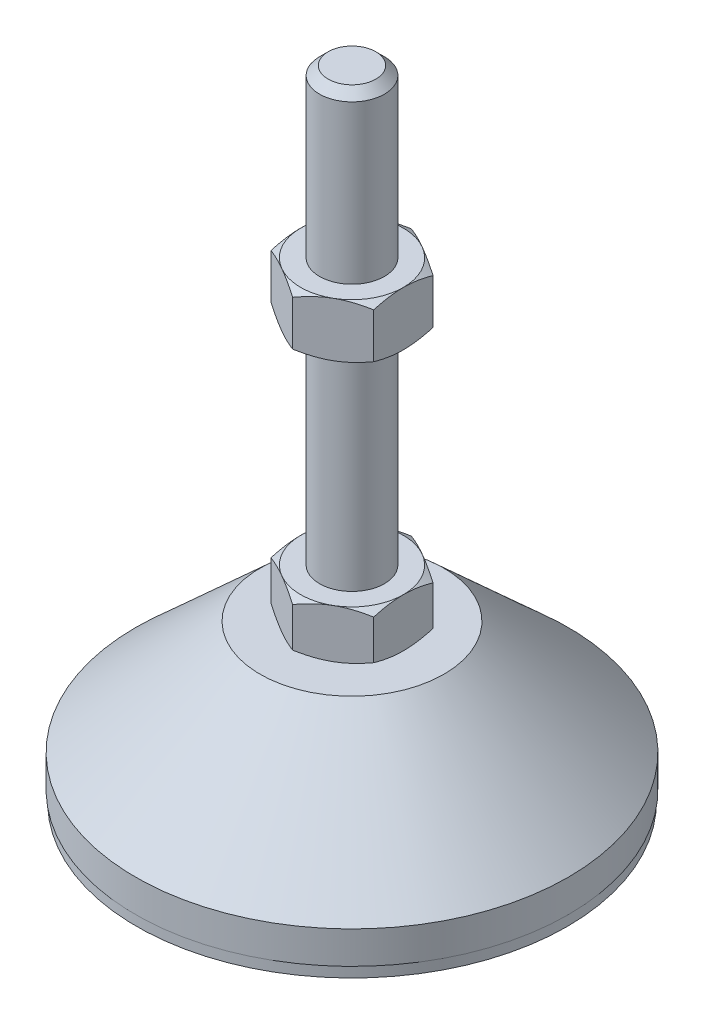
from build123d import *

# Parameters (mm, degrees)
EXTRUDE_1_DEPTH = 9
EXTRUDE_2_DEPTH = 10


with BuildPart() as part:
    # Эскиз1 → Повернуть1 (revolve)
    with BuildSketch(Plane.XY, mode=Mode.PRIVATE) as revolve_1_sk:
        Polygon((0, 0), (-39.8, 0), (-39.8, 2), (-40, 2), (-40, 8), (-17, 29), (-6, 29), (-6, 38), (-6, 116.4), (-4.4, 118), (0, 118), align=None)
    revolve(revolve_1_sk.sketch.rotate(Axis((0, 0, 0), (0, 1, 0)), 180), axis=Axis((0, 0, 0), (0, 1, 0)))  # turned: the seam where the file's is

    # Эскиз2 → Бобышка-Вытянуть1 (add)
    with BuildSketch(Plane(origin=(0, 29, 0), x_dir=(1, 0, 0), z_dir=(0, 1, 0))):
        Polygon((0, 10.969655115), (-9.5, 5.484827557), (-9.5, -5.484827557), (0, -10.969655115), (9.5, -5.484827557), (9.5, 5.484827557), align=None)
    extrude(amount=EXTRUDE_1_DEPTH)

    # Эскиз3 → Бобышка-Вытянуть2 (add)
    with BuildSketch(Plane(origin=(0, 77.2, 0), x_dir=(1, 0, 0), z_dir=(0, 1, 0))):
        Polygon((9.5, 5.484827557), (0, 10.969655115), (-9.5, 5.484827557), (-9.5, -5.484827557), (0, -10.969655115), (9.5, -5.484827557), align=None)
    extrude(amount=EXTRUDE_2_DEPTH)

    # Эскиз4 → Вырез-Повернуть2 (revolve, cut)
    with BuildSketch(Plane.XY, mode=Mode.PRIVATE) as cut_revolve_2_sk:
        Polygon((-18.160254038, 87.2), (-9.5, 87.2), (-18.160254038, 82.2), align=None)
        Polygon((-18.160254038, 77.2), (-18.160254038, 82.2), (-9.5, 77.2), align=None)
        Polygon((-17.294228634, 38), (-17.294228634, 33.5), (-9.5, 38), align=None)
        Polygon((-17.294228634, 33.5), (-17.294228634, 29), (-9.5, 29), align=None)
    revolve(cut_revolve_2_sk.sketch.rotate(Axis((0, 118, 0), (0, -1, 0)), 180), axis=Axis((0, 118, 0), (0, -1, 0)), mode=Mode.SUBTRACT)  # turned: the seam where the file's is


solid = part.part
